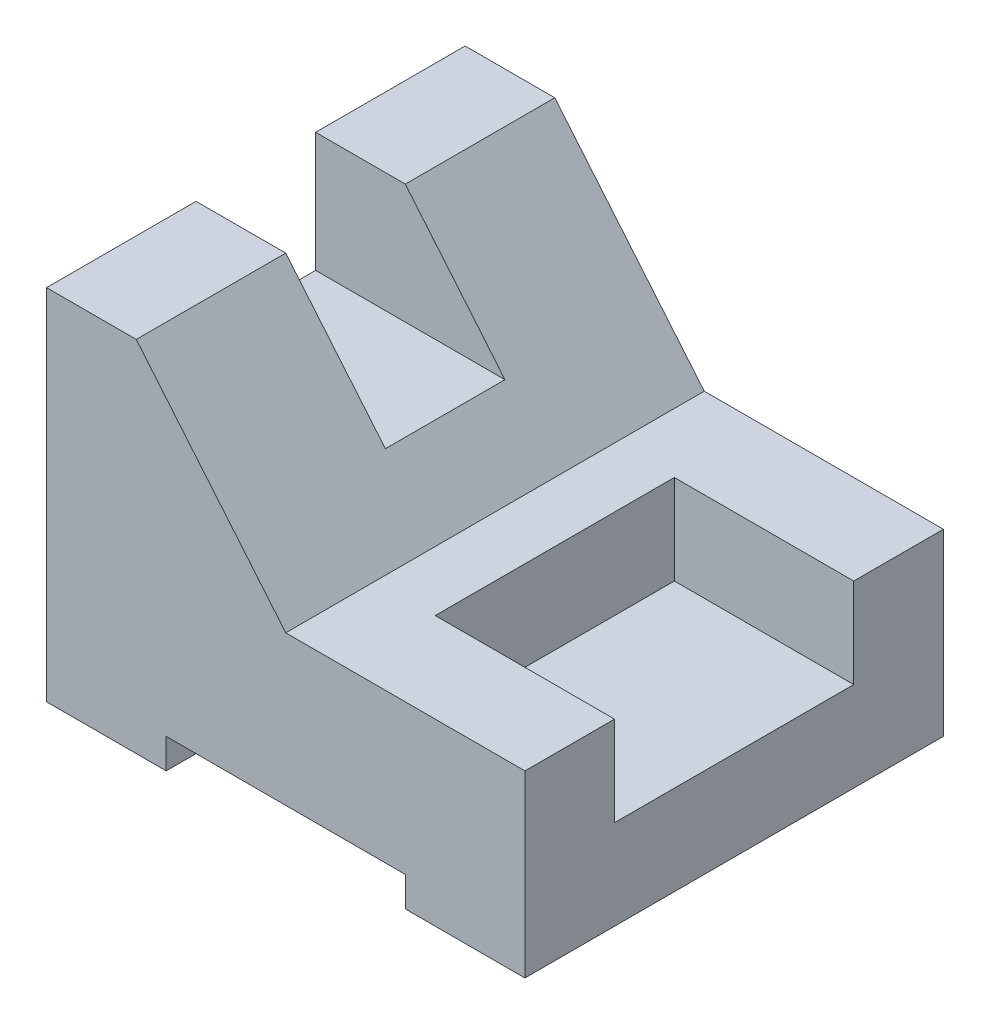
from build123d import *

# Parameters (mm, degrees)
BOSS_EXTRUDE1_DEPTH = 35
CUT_EXTRUDE1_DEPTH  = 10
SKETCH3_W           = 30
SKETCH3_H           = 15
CUT_EXTRUDE2_DEPTH  = 20


with BuildPart() as part:
    # Sketch1 → Boss-Extrude1 (new body, symmetric)
    with BuildSketch(Plane.XY):
        Polygon((0, 0), (0, 60), (15, 60), (40, 30), (80, 30), (80, 0), (60, 0), (60, 5), (20, 5), (20, 0), align=None)
    extrude(amount=BOSS_EXTRUDE1_DEPTH, both=True)

    # Sketch2 → Cut-Extrude1 (cut, symmetric)
    with BuildSketch(Plane.XY):
        Polygon((15, 60), (0, 60), (0, 40), (31.666666667, 40), align=None)
    extrude(amount=CUT_EXTRUDE1_DEPTH, both=True, mode=Mode.SUBTRACT)

    # Sketch3 → Cut-Extrude2 (cut, symmetric)
    with BuildSketch(Plane.XY):
        with Locations((65, 22.5)):
            Rectangle(SKETCH3_W, SKETCH3_H)
    extrude(amount=CUT_EXTRUDE2_DEPTH, both=True, mode=Mode.SUBTRACT)


solid = part.part
